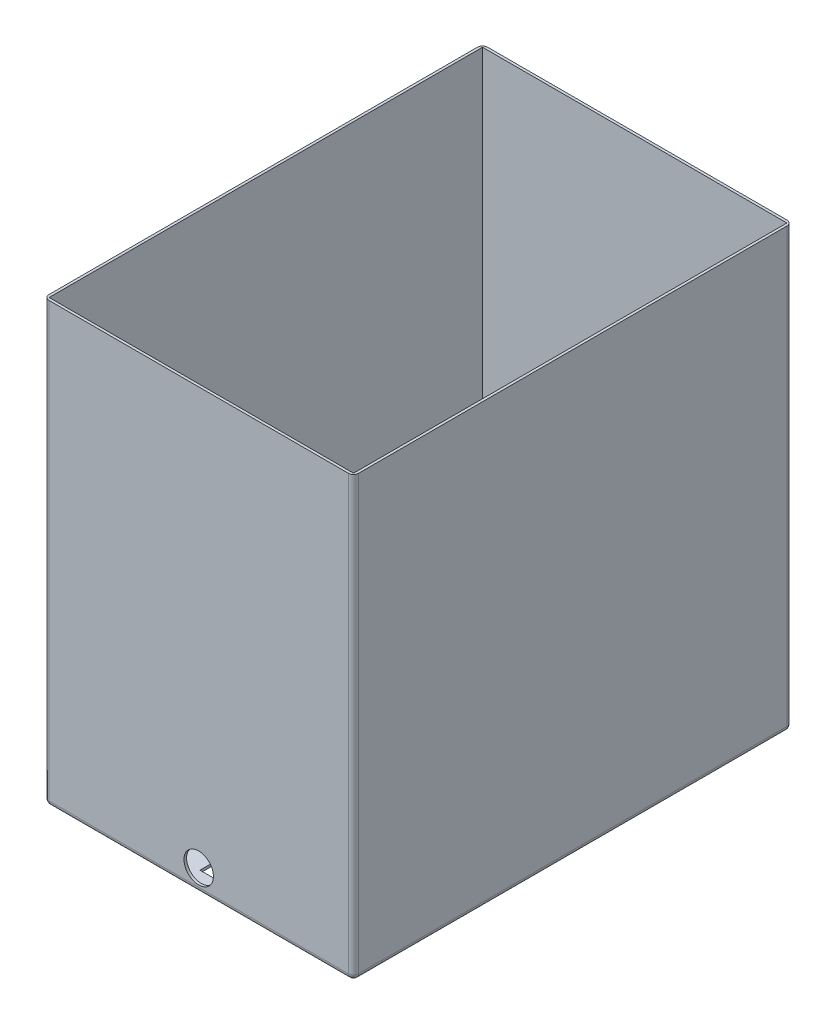
from build123d import *

# Parameters (mm, degrees)
SKETCH1_W           = 304.8
SKETCH1_H           = 431.8
BOSS_EXTRUDE1_DEPTH = 431.8
SKETCH2_W           = 299.72
SKETCH2_H           = 426.72
CUT_EXTRUDE1_DEPTH  = 429.26
FILLET1_R           = 5.08
SKETCH3_W           = 33.02
SKETCH3_H           = 86.106
CUT_EXTRUDE2_DEPTH  = 3.54
SKETCH10_R          = 14.478
CUT_EXTRUDE7_DEPTH  = 7.62


with BuildPart() as part:
    # Sketch1 → Boss-Extrude1 (new body)
    with BuildSketch(Plane.XY):
        with Locations((152.4, 215.9)):
            Rectangle(SKETCH1_W, SKETCH1_H)
    extrude(amount=BOSS_EXTRUDE1_DEPTH)

    # Sketch2 → Cut-Extrude1 (cut)
    with BuildSketch(Plane(origin=(0, 431.8, 0), x_dir=(1, 0, 0), z_dir=(0, 1, 0))):
        with Locations((152.4, -215.9)):
            Rectangle(SKETCH2_W, SKETCH2_H)
    extrude(amount=-CUT_EXTRUDE1_DEPTH, mode=Mode.SUBTRACT)

    # Fillet1
    fillet1_edges = [part.edges().sort_by_distance(p)[0] for p in [
        (304.8, 215.9, 431.8),
        (0, 215.9, 431.8),
        (304.8, 215.9, 0),
        (152.4, 0, 0),
        (0, 215.9, 0),
        (304.8, 0, 215.9),
        (0, 0, 215.9),
        (152.4, 0, 431.8),
    ]]
    fillet(fillet1_edges, radius=FILLET1_R)

    # Sketch3 → Cut-Extrude2 (cut, through all)
    with BuildSketch(Plane(origin=(0, 2.54, 0), x_dir=(1, 0, 0), z_dir=(0, 1, 0))):
        with Locations((152.4, -370.967)):
            Rectangle(SKETCH3_W, SKETCH3_H)
    extrude(amount=-CUT_EXTRUDE2_DEPTH, mode=Mode.SUBTRACT)

    # Sketch10 → Cut-Extrude7 (cut)
    with BuildSketch(Plane.XY.offset(431.8)):
        with Locations((152.4, 21.59)):
            Circle(SKETCH10_R)
    extrude(amount=-CUT_EXTRUDE7_DEPTH, mode=Mode.SUBTRACT)


solid = part.part
